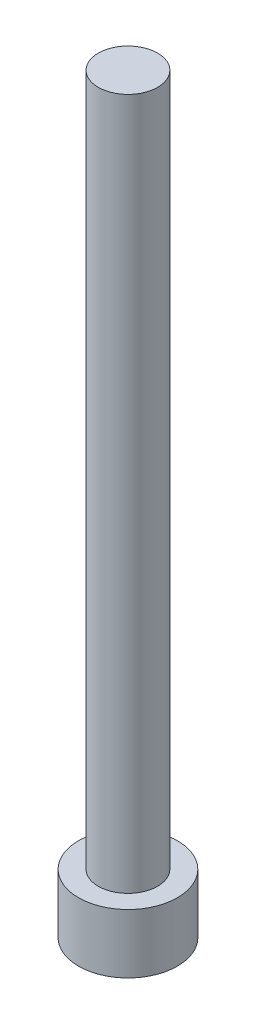
from build123d import *

# Parameters (mm, degrees)
SKETCH_1_R          = 2.5
EXTRUDE_1_DEPTH     = 3
SKETCH_2_R          = 1.5
EXTRUDE_2_DEPTH     = 35
CUT_EXTRUDE_1_DEPTH = 1.65


with BuildPart() as part:
    # 草图1 → 凸台-拉伸1 (new body)
    with BuildSketch(Plane(origin=(0, 0, 0), x_dir=(1, 0, 0), z_dir=(0, 1, 0))):
        Circle(SKETCH_1_R)
    extrude(amount=EXTRUDE_1_DEPTH)

    # 草图2 → 凸台-拉伸2 (add)
    with BuildSketch(Plane(origin=(0, 3, 0), x_dir=(1, 0, 0), z_dir=(0, 1, 0))):
        Circle(SKETCH_2_R)
    extrude(amount=EXTRUDE_2_DEPTH)

    # 草图3 → 切除-拉伸1 (cut)
    with BuildSketch(Plane.XZ):
        Polygon((1.425, 0), (0.7125, 1.2340862), (-0.7125, 1.2340862), (-1.425, 0), (-0.7125, -1.2340862), (0.7125, -1.2340862), align=None)
    extrude(amount=-CUT_EXTRUDE_1_DEPTH, mode=Mode.SUBTRACT)


solid = part.part
